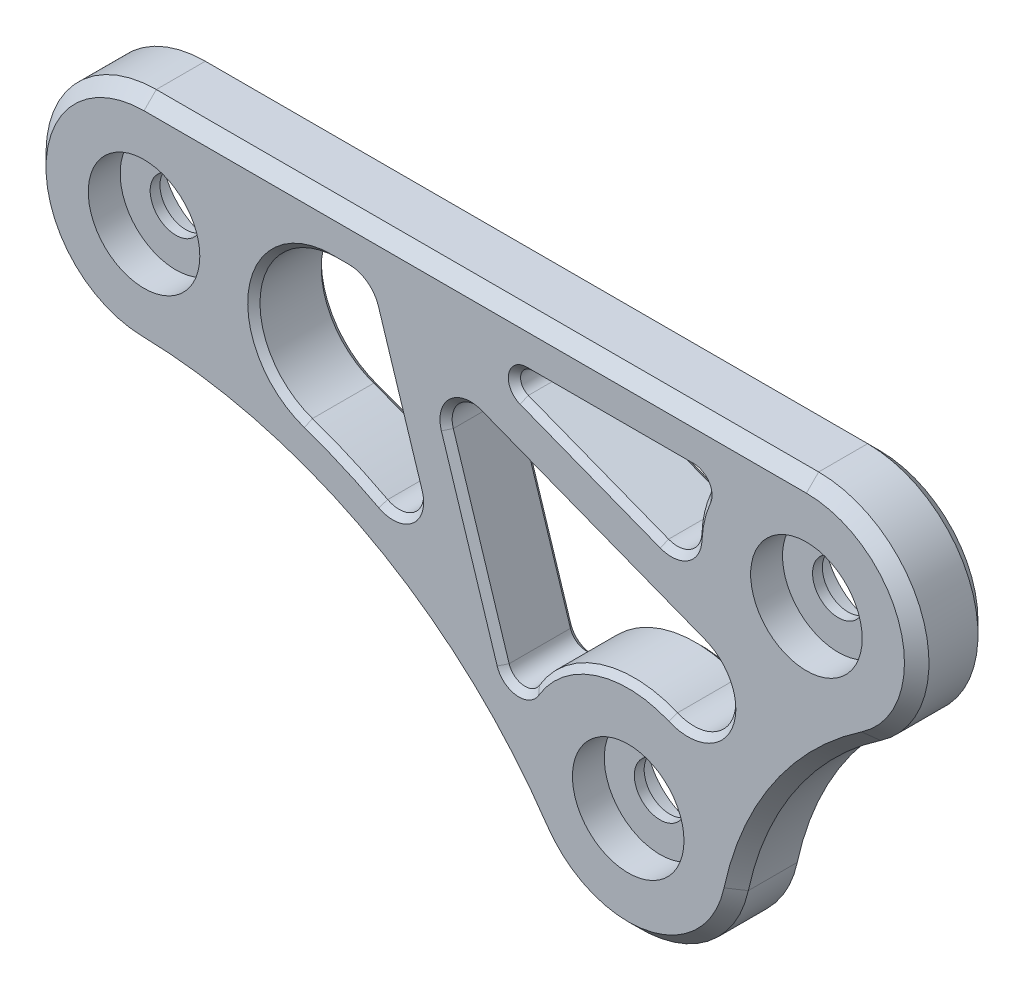
from build123d import *

# Parameters (mm, degrees)
BOSS_EXTRUDE1_DEPTH      = 3
BOSS_EXTRUDE1_DEPTH_BACK = 3
SKETCH1_R                = 2.1
SKETCH2_R                = 4.55
CUT_EXTRUDE1_DEPTH       = 2.6
CHAMFER1_SIZE            = 1
CUT_EXTRUDE2_DEPTH       = 58.636966268
CHAMFER2_SIZE            = 0.5


with BuildPart() as part:
    # Sketch1 → Boss-Extrude1 (new, two sides: drawn at the far end of the back side and taken through both)
    with BuildSketch(Plane.XY.offset(-BOSS_EXTRUDE1_DEPTH_BACK)):
        with BuildLine():
            Line((-39.501683147, 30.554976886), (14.53901549, 30.554976886))
            ThreePointArc((14.53901549, 30.554976886), (23.141239174, 24.201058459), (19.597278951, 14.110920817))
            ThreePointArc((19.597278951, 14.110920817), (12.655063172, 7.14488544), (8.796867444, -1.901347727))
            ThreePointArc((8.796867444, -1.901347727), (1.705655337, -8.836896507), (-7.457341048, -5.038657013))
            ThreePointArc((-7.457341048, -5.038657013), (-21.441099585, 7.679919061), (-39.703613005, 12.557242486))
            ThreePointArc((-39.703613005, 12.557242486), (-48.501116729, 21.65594817), (-39.501683147, 30.554976886))
        make_face()
        Circle(SKETCH1_R, mode=Mode.SUBTRACT)
        with Locations((-39.501683147, 21.554976886)):
            Circle(SKETCH1_R, mode=Mode.SUBTRACT)
        with Locations((14.53901549, 21.554976886)):
            Circle(SKETCH1_R, mode=Mode.SUBTRACT)
    extrude(amount=BOSS_EXTRUDE1_DEPTH + BOSS_EXTRUDE1_DEPTH_BACK)

    # Sketch2 → Cut-Extrude1 (cut)
    with BuildSketch(Plane.XY.offset(3)):
        with Locations((-39.501683147, 21.554976886)):
            Circle(SKETCH2_R)
        with Locations((14.53901549, 21.554976886)):
            Circle(SKETCH2_R)
        Circle(SKETCH2_R)
    cut_extrude1 = extrude(amount=-CUT_EXTRUDE1_DEPTH, mode=Mode.SUBTRACT)

    # Mirror1: Cut-Extrude1 across plane
    add(cut_extrude1.mirror(Plane.XY), mode=Mode.SUBTRACT)

    # Chamfer1
    chamfer1_edges = [part.edges().sort_by_distance(p)[0] for p in [
        (1.705655337, -8.836896507, -3),
        (12.655063172, 7.14488544, -3),
        (-21.441099585, 7.679919061, -3),
        (23.141239174, 24.201058459, -3),
        (-48.501116729, 21.65594817, -3),
        (-12.481333828, 30.554976886, -3),
        (1.705655337, -8.836896507, 3),
        (12.655063172, 7.14488544, 3),
        (-21.441099585, 7.679919061, 3),
        (23.141239174, 24.201058459, 3),
        (-48.501116729, 21.65594817, 3),
        (-12.481333828, 30.554976886, 3),
    ]]
    chamfer(chamfer1_edges, length=CHAMFER1_SIZE)

    # Sketch3 → Cut-Extrude2 (cut, through all)
    with BuildSketch(Plane.XY.offset(3)):
        with BuildLine():
            Line((-24.180281108, 26.554976886), (-22.764342389, 26.554976886))
            ThreePointArc((-22.764342389, 26.554976886), (-21.583396496, 26.169091752), (-20.858160069, 25.160343686))
            Line((-20.858160069, 25.160343686), (-17.281431039, 13.89791957))
            ThreePointArc((-17.281431039, 13.89791957), (-17.903964164, 11.758849819), (-20.119238586, 11.522785996))
            ThreePointArc((-20.119238586, 11.522785996), (-23.13863628, 12.96831982), (-26.259194014, 14.180115968))
            ThreePointArc((-26.259194014, 14.180115968), (-30.454415742, 21.246945404), (-24.180281108, 26.554976886))
        make_face()
        with BuildLine():
            Line((-8.643875433, 24.622717198), (2.795841433, 20.183210519))
            ThreePointArc((2.795841433, 20.183210519), (4.612056387, 20.372573761), (5.51742454, 21.958387022))
            ThreePointArc((5.51742454, 21.958387022), (5.741336481, 23.592791168), (6.25883004, 25.159192739))
            ThreePointArc((6.25883004, 25.159192739), (6.178513352, 26.104179516), (5.344107869, 26.554976886))
            Line((5.344107869, 26.554976886), (-8.282085612, 26.554976886))
            ThreePointArc((-8.282085612, 26.554976886), (-9.265004655, 25.73901535), (-8.643875433, 24.622717198))
        make_face()
        with BuildLine():
            Line((-14.767813151, 19.218195089), (-10.2137058, 4.878196721))
            ThreePointArc((-10.2137058, 4.878196721), (-9.068134637, 3.935197355), (-7.738892439, 4.594512359))
            ThreePointArc((-7.738892439, 4.594512359), (-2.798782744, 8.553760293), (3.526217449, 8.280446274))
            ThreePointArc((3.526217449, 8.280446274), (8.030102489, 10.136580166), (6.10124738, 14.609803998))
            Line((6.10124738, 14.609803998), (-12.138051189, 21.688081264))
            ThreePointArc((-12.138051189, 21.688081264), (-14.230835601, 21.281395314), (-14.767813151, 19.218195089))
        make_face()
    extrude(amount=-CUT_EXTRUDE2_DEPTH, mode=Mode.SUBTRACT)

    # Chamfer2
    chamfer2_edges = [part.edges().sort_by_distance(p)[0] for p in [
        (6.178513352, 26.104179516, -3),
        (-1.468988872, 26.554976886, -3),
        (5.741336481, 23.592791168, -3),
        (-9.265004655, 25.73901535, -3),
        (4.612056387, 20.372573761, -3),
        (-2.924017, 22.402963859, -3),
        (6.178513352, 26.104179516, 3),
        (-1.468988872, 26.554976886, 3),
        (5.741336481, 23.592791168, 3),
        (-9.265004655, 25.73901535, 3),
        (4.612056387, 20.372573761, 3),
        (-2.924017, 22.402963859, 3),
        (-30.454415742, 21.246945404, -3),
        (-23.13863628, 12.96831982, -3),
        (-23.472311748, 26.554976886, -3),
        (-17.903964164, 11.758849819, -3),
        (-21.583396496, 26.169091752, -3),
        (-19.069795554, 19.529131628, -3),
        (-30.454415742, 21.246945404, 3),
        (-23.13863628, 12.96831982, 3),
        (-23.472311748, 26.554976886, 3),
        (-17.903964164, 11.758849819, 3),
        (-21.583396496, 26.169091752, 3),
        (-19.069795554, 19.529131628, 3),
        (-14.230835601, 21.281395314, -3),
        (-12.490759475, 12.048195905, -3),
        (-3.018401905, 18.148942631, -3),
        (-9.068134637, 3.935197355, -3),
        (8.030102489, 10.136580166, -3),
        (-2.798782744, 8.553760293, -3),
        (-14.230835601, 21.281395314, 3),
        (-12.490759475, 12.048195905, 3),
        (-3.018401905, 18.148942631, 3),
        (-9.068134637, 3.935197355, 3),
        (8.030102489, 10.136580166, 3),
        (-2.798782744, 8.553760293, 3),
    ]]
    chamfer(chamfer2_edges, length=CHAMFER2_SIZE)


solid = part.part
